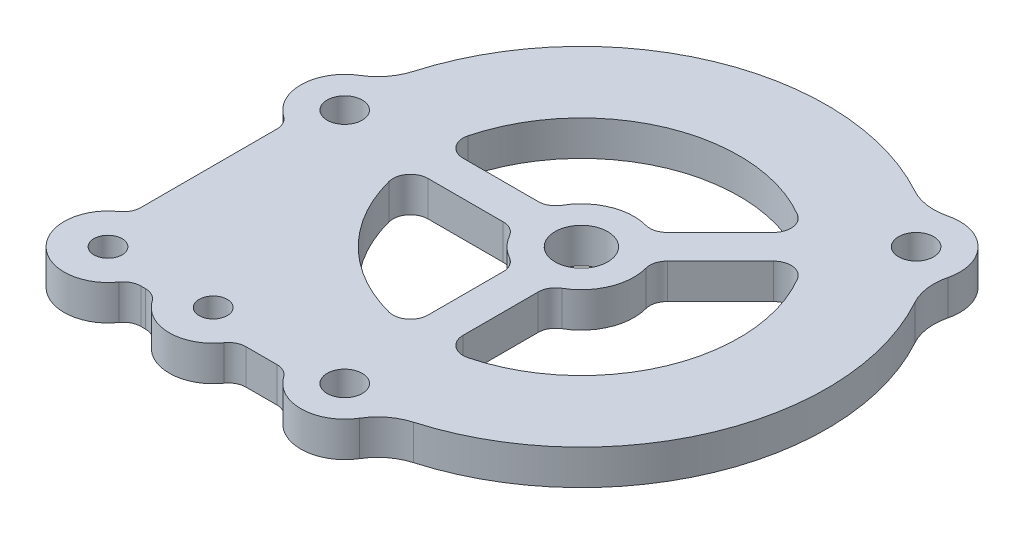
from build123d import *

# Parameters (mm, degrees)
BOSS_EXTRUDE1_DEPTH         = 6.35
SKETCH2_R                   = 4.7625
CUT_EXTRUDE1_DEPTH          = 7.35
F_1_4_0_25_DIAMETER_HOLE1_D = 6.35
CUT_EXTRUDE2_DEPTH          = 7.35
FILLET1_R                   = 3.175
BOSS_EXTRUDE2_DEPTH         = 6.35
F_10_CLEARANCE_HOLE1_D      = 5.1054
CUT_EXTRUDE5_DEPTH          = 6.35
FILLET3_R                   = 3.175


with BuildPart() as part:
    # Sketch1 → Boss-Extrude1 (new body)
    with BuildSketch(Plane(origin=(0, 0, 0), x_dir=(1, 0, 0), z_dir=(0, 1, 0))):
        with BuildLine():
            ThreePointArc((-42.706862745, -12.325841735), (-31.430896424, -31.430896424), (-12.325841735, -42.706862745))
            ThreePointArc((-12.325841735, -42.706862745), (-9.162618669, -44.306267621), (-6.803224334, -46.951515152))
            ThreePointArc((-6.803224334, -46.951515152), (0, -50.8), (6.803224334, -46.951515152))
            ThreePointArc((6.803224334, -46.951515152), (9.162618669, -44.306267621), (12.325841735, -42.706862745))
            ThreePointArc((12.325841735, -42.706862745), (41.06644522, -17.010278569), (38.913998525, 21.482625976))
            ThreePointArc((38.913998525, 21.482625976), (37.808212078, 24.85031249), (38.010340811, 28.38912869))
            ThreePointArc((38.010340811, 28.38912869), (35.921024484, 35.921024484), (28.38912869, 38.010340811))
            ThreePointArc((28.38912869, 38.010340811), (24.85031249, 37.808212078), (21.482625976, 38.913998525))
            ThreePointArc((21.482625976, 38.913998525), (-17.010278569, 41.06644522), (-42.706862745, 12.325841735))
            ThreePointArc((-42.706862745, 12.325841735), (-44.306267621, 9.162618669), (-46.951515152, 6.803224334))
            ThreePointArc((-46.951515152, 6.803224334), (-50.8, 0), (-46.951515152, -6.803224334))
            ThreePointArc((-46.951515152, -6.803224334), (-44.306267621, -9.162618669), (-42.706862745, -12.325841735))
        make_face()
    extrude(amount=BOSS_EXTRUDE1_DEPTH)

    # Sketch2 → Cut-Extrude1 (cut, through all)
    with BuildSketch(Plane(origin=(0, 6.35, 0), x_dir=(1, 0, 0), z_dir=(0, 1, 0))):
        Circle(SKETCH2_R)
    extrude(amount=-CUT_EXTRUDE1_DEPTH, mode=Mode.SUBTRACT)

    # 1/4 (0.25) Diameter Hole1 (through all)
    with Locations(Plane(origin=(0, 6.35, 0), x_dir=(1, 0, 0), z_dir=(0, 1, 0))):
        with Locations((-42.8625, 0), (30.308364409, 30.308364409), (0, -42.8625)):
            Hole(F_1_4_0_25_DIAMETER_HOLE1_D / 2)

    # Sketch5 → Cut-Extrude2 (cut, through all)
    with BuildSketch(Plane(origin=(0, 6.35, 0), x_dir=(1, 0, 0), z_dir=(0, 1, 0))):
        with BuildLine():
            Line((-28.398063314, 3.175), (-8.980256121, 3.175))
            ThreePointArc((-8.980256121, 3.175), (-3.645059693, 8.799952547), (4.10493597, 8.59506403))
            Line((4.10493597, 8.59506403), (17.835399112, 22.325527172))
            ThreePointArc((17.835399112, 22.325527172), (-10.93517908, 26.399857642), (-28.398063314, 3.175))
        make_face()
        with BuildLine():
            Line((-28.398063314, -3.175), (-8.980256121, -3.175))
            ThreePointArc((-8.980256121, -3.175), (-6.735192091, -6.735192091), (-3.175, -8.980256121))
            Line((-3.175, -8.980256121), (-3.175, -28.398063314))
            ThreePointArc((-3.175, -28.398063314), (-20.205576272, -20.205576272), (-28.398063314, -3.175))
        make_face()
        with BuildLine():
            Line((22.325527172, 17.835399112), (8.59506403, 4.10493597))
            ThreePointArc((8.59506403, 4.10493597), (8.799952547, -3.645059693), (3.175, -8.980256121))
            Line((3.175, -8.980256121), (3.175, -28.398063314))
            ThreePointArc((3.175, -28.398063314), (26.399857642, -10.93517908), (22.325527172, 17.835399112))
        make_face()
    extrude(amount=-CUT_EXTRUDE2_DEPTH, mode=Mode.SUBTRACT)

    # Fillet1
    fillet1_edges = [part.edges().sort_by_distance(p)[0] for p in [
        (22.325527172, 3.175, -17.835399112),
        (3.175, 3.175, 28.398063314),
        (3.175, 3.175, 8.980256121),
        (8.59506403, 3.175, -4.10493597),
        (-3.175, 3.175, 28.398063314),
        (-28.398063314, 3.175, 3.175),
        (-8.980256121, 3.175, 3.175),
        (-3.175, 3.175, 8.980256121),
        (-28.398063314, 3.175, -3.175),
        (17.835399112, 3.175, -22.325527172),
        (4.10493597, 3.175, -8.59506403),
        (-8.980256121, 3.175, -3.175),
    ]]
    fillet(fillet1_edges, radius=FILLET1_R)

    # Sketch8 → Boss-Extrude2 (add)
    with BuildSketch(Plane(origin=(0, 6.35, 0), x_dir=(1, 0, 0), z_dir=(0, 1, 0))):
        with BuildLine():
            Line((-50.8, 0), (-50.8, -42.8625))
            ThreePointArc((-50.8, -42.8625), (-48.475160076, -48.475160076), (-42.8625, -50.8))
            Line((-42.8625, -50.8), (0, -50.8))
            ThreePointArc((0, -50.8), (-3.908154839, -49.771206971), (-6.803224334, -46.951515152))
            ThreePointArc((-6.803224334, -46.951515152), (-9.162618669, -44.306267621), (-12.325841735, -42.706862745))
            ThreePointArc((-12.325841735, -42.706862745), (-31.430896424, -31.430896424), (-42.706862745, -12.325841735))
            ThreePointArc((-42.706862745, -12.325841735), (-44.306267621, -9.162618669), (-46.951515152, -6.803224334))
            ThreePointArc((-46.951515152, -6.803224334), (-49.771206971, -3.908154839), (-50.8, 0))
        make_face()
    extrude(amount=-BOSS_EXTRUDE2_DEPTH)

    # #10 Clearance Hole1 (through all)
    with Locations(Plane(origin=(0, 6.35, 0), x_dir=(1, 0, 0), z_dir=(0, 1, 0))):
        with Locations((-42.8625, -42.8625), (-23.8125, -42.8625)):
            Hole(F_10_CLEARANCE_HOLE1_D / 2)

    # Sketch15 → Cut-Extrude5 (cut)
    with BuildSketch(Plane(origin=(0, 6.35, 0), x_dir=(1, 0, 0), z_dir=(0, 1, 0))):
        with BuildLine():
            ThreePointArc((-46.0375, -35.587661084), (-49.503488961, -38.5149522), (-50.8, -42.8625))
            Line((-50.8, -42.8625), (-50.8, 0))
            ThreePointArc((-50.8, 0), (-49.503488961, -4.3475478), (-46.0375, -7.274838916))
            Line((-46.0375, -7.274838916), (-46.0375, -35.587661084))
        make_face()
        with BuildLine():
            Line((-31.087338916, -46.0375), (-35.587661084, -46.0375))
            ThreePointArc((-35.587661084, -46.0375), (-38.5149522, -49.503488961), (-42.8625, -50.8))
            Line((-42.8625, -50.8), (-23.8125, -50.8))
            ThreePointArc((-23.8125, -50.8), (-28.1600478, -49.503488961), (-31.087338916, -46.0375))
        make_face()
        with BuildLine():
            ThreePointArc((-16.537661084, -46.0375), (-19.4649522, -49.503488961), (-23.8125, -50.8))
            Line((-23.8125, -50.8), (0, -50.8))
            ThreePointArc((0, -50.8), (-4.3475478, -49.503488961), (-7.274838916, -46.0375))
            Line((-7.274838916, -46.0375), (-16.537661084, -46.0375))
        make_face()
    extrude(amount=-CUT_EXTRUDE5_DEPTH, mode=Mode.SUBTRACT)

    # Fillet3
    fillet3_edges = [part.edges().sort_by_distance(p)[0] for p in [
        (-46.0375, 3.175, 35.587661084),
        (-46.0375, 3.175, 7.274838916),
        (-35.587661084, 3.175, 46.0375),
        (-31.087338916, 3.175, 46.0375),
        (-16.537661084, 3.175, 46.0375),
        (-7.274838916, 3.175, 46.0375),
    ]]
    fillet(fillet3_edges, radius=FILLET3_R)


solid = part.part
